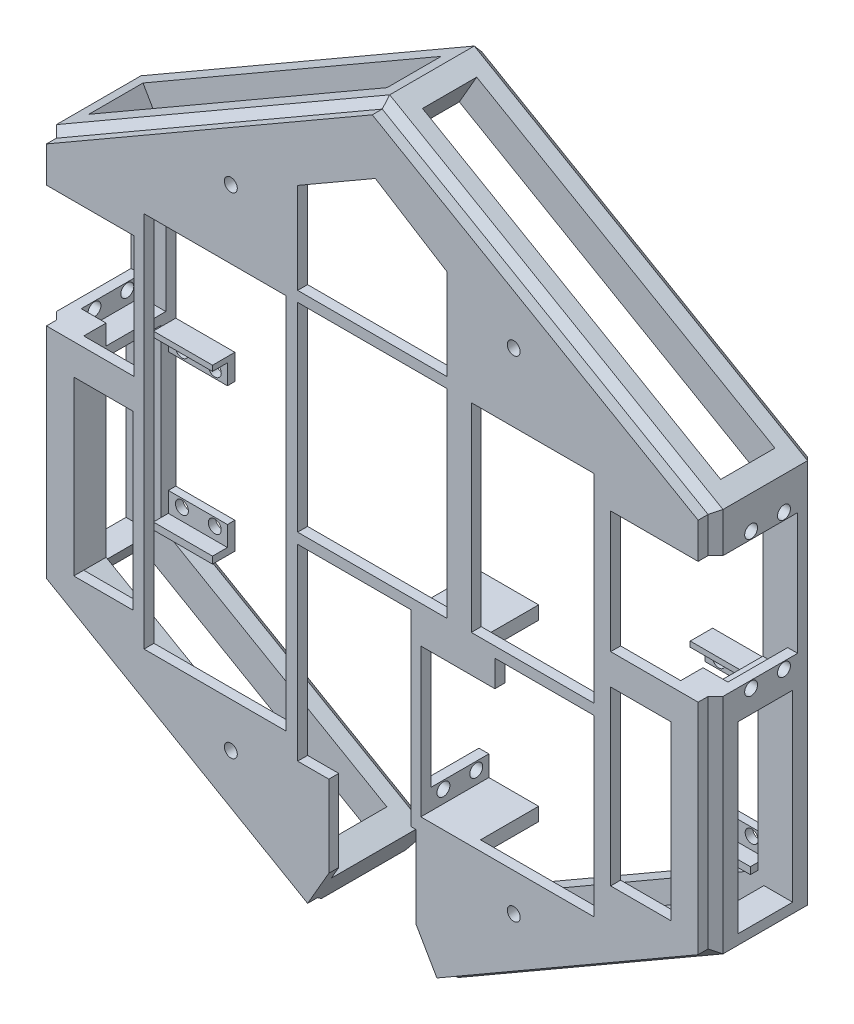
from build123d import *

# Parameters (mm, degrees)
BOSS_EXTRU_1_DEPTH           = 20
CHANFREIN1_SIZE              = 1.5
ESQUISSE4_W                  = 20
ESQUISSE4_H                  = 24.5
ENL_V_MAT_EXTRU_1_DEPTH      = 202.172397046
ENL_V_MAT_EXTRU_1_DEPTH_BACK = 10
ESQUISSE8_W                  = 10.9
ESQUISSE8_H                  = 69.214936071
ENL_V_MAT_EXTRU_3_DEPTH      = 7
ESQUISSE9_W                  = 10.9
ESQUISSE9_H                  = 69.214936071
ENL_V_MAT_EXTRU_4_DEPTH      = 7
ESQUISSE11_W                 = 11
ESQUISSE11_H                 = 69.214936071
ENL_V_MAT_EXTRU_5_DEPTH      = 7
ESQUISSE10_W                 = 11
ESQUISSE10_H                 = 69.214936071
ENL_V_MAT_EXTRU_6_DEPTH      = 7
BOSS_EXTRU_2_DEPTH           = 2
ESQUISSE18_W                 = 18.5
ESQUISSE18_H                 = 34.630653181
BOSS_EXTRU_5_DEPTH           = 30
ENL_V_START                  = -10
ESQUISSE20_W                 = 30
ESQUISSE20_H                 = 34.630653181
ENL_V_MAT_EXTRU_9_DEPTH      = 24
ENL_V_MAT_EXTRU_8_REACH      = 171.855
ESQUISSE19_W                 = 12.084
ESQUISSE19_H                 = 24.149
ESQUISSE22_W                 = 4.5
ESQUISSE22_H                 = 34.630653181
ENL_V_MAT_EXTRU_10_DEPTH     = 17.916
ESQUISSE23_W                 = 2
ESQUISSE23_H                 = 34.630653181
BOSS_EXTRU_6_DEPTH           = 17.916
ENL_V_MAT_EXTRU_11_REACH     = 171.855
ESQUISSE21_R                 = 1.3
ESQUISSE24_W                 = 12.084
ESQUISSE24_H                 = 4
ENL_V_MAT_EXTRU_12_DEPTH     = 3
ENL_V_START_2                = -18.116
ESQUISSE25_W                 = 4.5
ESQUISSE25_H                 = 34.630653181
ENL_V_MAT_EXTRU_13_DEPTH     = 18.116
ESQUISSE26_W                 = 2
ESQUISSE26_H                 = 34.630653181
BOSS_EXTRU_7_DEPTH           = 18.116
ENL_V_MAT_EXTRU_14_REACH     = 207.867
ESQUISSE27_R                 = 1.3
ENL_V_MAT_EXTRU_15_REACH     = 172.042
ESQUISSE28_W                 = 17.584
ESQUISSE28_H                 = 24.5
ESQUISSE29_W                 = 12.011314892
ESQUISSE29_H                 = 4
ENL_V_MAT_EXTRU_16_DEPTH     = 5
ESQUISSE30_W                 = 26.891
ESQUISSE30_H                 = 37.749
BOSS_EXTRU_8_DEPTH           = 13.684
ESQUISSE31_W                 = 11.684
ESQUISSE31_H                 = 37.749
ENL_V_MAT_EXTRU_18_DEPTH     = 10
ESQUISSE32_W                 = 16.891
ESQUISSE32_H                 = 24.149
ENL_V_MAT_EXTRU_19_DEPTH     = 11.684
ESQUISSE33_W                 = 14.891
ESQUISSE33_H                 = 6.8
ENL_V_MAT_EXTRU_20_DEPTH     = 11.684
ESQUISSE34_W                 = 11.684
ESQUISSE34_H                 = 2.682
BOSS_EXTRU_9_DEPTH           = 10
ESQUISSE35_R                 = 1.3
ENL_V_MAT_EXTRU_21_DEPTH     = 10
ESQUISSE36_W                 = 14.891
ESQUISSE36_H                 = 29.745214719
ENL_V_MAT_EXTRU_22_DEPTH     = 10
ESQUISSE37_R                 = 1.3
ENL_V_MAT_EXTRU_23_DEPTH     = 5
ENL_V_MAT_EXTRU_24_REACH     = 171.795
ESQUISSE38_W                 = 30
ESQUISSE38_H                 = 40
ENL_V_MAT_EXTRU_25_REACH     = 207.867
ESQUISSE39_W                 = 11
ESQUISSE39_H                 = 36.905484187
ESQUISSE40_W                 = 11
ESQUISSE40_H                 = 36.905484187
ENL_V_MAT_EXTRU_26_DEPTH     = 7
ESQUISSE41_W                 = 15
ESQUISSE41_H                 = 22
ENL_V_MAT_EXTRU_27_DEPTH     = 10
ESQUISSE42_W                 = 15
ESQUISSE42_H                 = 22
ENL_V_MAT_EXTRU_28_DEPTH     = 10
ESQUISSE43_W                 = 4.359796613
ESQUISSE43_H                 = 21.511824703
ENL_V_MAT_EXTRU_29_DEPTH     = 10
BOSS_EXTRU_10_REACH          = 164.107
ESQUISSE45_W                 = 24.622278159
ESQUISSE45_H                 = 40
ESQUISSE45_W_2               = 28.545366006
ESQUISSE45_H_2               = 75.789830022
ESQUISSE45_W_3               = 19.879423901
ESQUISSE45_H_3               = 35.067
ENL_V_MAT_EXTRU_33_DEPTH     = 10


with BuildPart() as part:
    # Esquisse1 → Boss.-Extru.1 (new body)
    with BuildSketch(Plane.XY):
        Polygon((-67, -38.682468036), (0, 0), (67, -38.682468036), (67, -116.047404107), (0, -154.729872143), (-67, -116.047404107), align=None)
        Polygon((0, -8.082903769), (60, -42.72391992), (60, -112.005952223), (0, -146.646968374), (-60, -112.005952223), (-60, -42.72391992), align=None, mode=Mode.SUBTRACT)
    extrude(amount=BOSS_EXTRU_1_DEPTH)

    # Chanfrein1
    chanfrein1_edges = [part.edges().sort_by_distance(p)[0] for p in [
        (33.5, -135.388638125, 20),
        (67, -77.364936071, 20),
        (33.5, -19.341234018, 20),
        (-33.5, -19.341234018, 20),
        (-30, -25.403411844, 0),
        (-60, -77.364936071, 0),
        (-30, -129.326460298, 0),
        (30, -129.326460298, 0),
        (60, -77.364936071, 0),
        (30, -25.403411844, 0),
        (-67, -77.364936071, 20),
        (-33.5, -19.341234018, 0),
        (33.5, -19.341234018, 0),
        (67, -77.364936071, 0),
        (-33.5, -135.388638125, 20),
        (33.5, -135.388638125, 0),
        (-33.5, -135.388638125, 0),
        (-67, -77.364936071, 0),
    ]]
    chamfer(chanfrein1_edges, length=CHANFREIN1_SIZE)

    # Esquisse4 → Enlèv. mat.-Extru.1 (cut, two sides)
    with BuildSketch(Plane(origin=(-60, 0, 0), x_dir=(0, 0, -1), z_dir=(1, 0, 0))) as enl_v_mat_extru_1_sk:
        with Locations((-13.5, -58.97391992)):
            Rectangle(ESQUISSE4_W, ESQUISSE4_H)
    extrude(amount=ENL_V_MAT_EXTRU_1_DEPTH, mode=Mode.SUBTRACT)
    extrude(enl_v_mat_extru_1_sk.sketch, amount=-ENL_V_MAT_EXTRU_1_DEPTH_BACK, mode=Mode.SUBTRACT)

    # Esquisse8 → Enlèv. mat.-Extru.3 (cut)
    with BuildSketch(Plane(origin=(0, 0, 0), x_dir=(0, 0, 1), z_dir=(-0.49999999999998623, 0.8660254037844466, 0))):
        with Locations((10, -38.757468036)):
            Rectangle(ESQUISSE8_W, ESQUISSE8_H)
    extrude(amount=-ENL_V_MAT_EXTRU_3_DEPTH, mode=Mode.SUBTRACT)

    # Esquisse9 → Enlèv. mat.-Extru.4 (cut)
    with BuildSketch(Plane(origin=(0, 0, 0), x_dir=(0, 0, -1), z_dir=(0.4999999999999863, 0.8660254037844466, 0))):
        with Locations((-10.05, -38.757468036)):
            Rectangle(ESQUISSE9_W, ESQUISSE9_H)
    extrude(amount=-ENL_V_MAT_EXTRU_4_DEPTH, mode=Mode.SUBTRACT)

    # Esquisse11 → Enlèv. mat.-Extru.5 (cut)
    with BuildSketch(Plane(origin=(67, -116.047404107, 0), x_dir=(0, 0, -1), z_dir=(0.499999999999995, -0.8660254037844415, 0))):
        with Locations((-10, -38.607468036)):
            Rectangle(ESQUISSE11_W, ESQUISSE11_H)
    extrude(amount=-ENL_V_MAT_EXTRU_5_DEPTH, mode=Mode.SUBTRACT)

    # Esquisse10 → Enlèv. mat.-Extru.6 (cut)
    with BuildSketch(Plane(origin=(-67, -116.047404107, 0), x_dir=(0, 0, 1), z_dir=(-0.500000000000004, -0.8660254037844363, 0))):
        with Locations((10, -38.257468036)):
            Rectangle(ESQUISSE10_W, ESQUISSE10_H)
    extrude(amount=-ENL_V_MAT_EXTRU_6_DEPTH, mode=Mode.SUBTRACT)

    # Esquisse13 → Boss.-Extru.2 (add)
    with BuildSketch(Plane.XY.offset(20)):
        Polygon((65.5, -115.181378703), (65.5, -39.548493439), (0, -1.732050808), (-65.5, -39.548493439), (-65.5, -115.181378703), (0, -152.997821335), align=None)
    extrude(amount=BOSS_EXTRU_2_DEPTH)

    # Esquisse18 → Boss.-Extru.5 (add)
    with BuildSketch(Plane.ZY.offset(-60)):
        with Locations((10.75, -94.690625633)):
            Rectangle(ESQUISSE18_W, ESQUISSE18_H)
    boss_extru_5 = extrude(amount=BOSS_EXTRU_5_DEPTH)

    # Symétrie5: Boss.-Extru.5 across plane
    add(boss_extru_5.mirror(Plane(origin=(0, 0, 0), x_dir=(0, 0, 1), z_dir=(1, 0, 0))))

    # Esquisse20 → Enlèv. mat.-Extru.9 (cut)
    with BuildSketch(Plane(origin=(0, 0, 20), x_dir=(-1, 0, 0), z_dir=(0, 0, -1)).offset(ENL_V_START)):
        with Locations((-45, -94.690625633)):
            Rectangle(ESQUISSE20_W, ESQUISSE20_H)
    enl_v_mat_extru_9 = extrude(amount=ENL_V_MAT_EXTRU_9_DEPTH, mode=Mode.SUBTRACT)

    # Esquisse19 → Enlèv. mat.-Extru.8 (cut, up to next)
    with BuildSketch(Plane(origin=(0, 0, 1.5), x_dir=(-1, 0, 0), z_dir=(0, 0, -1)), mode=Mode.PRIVATE) as enl_v_mat_extru_8_sk1:
        with Locations((-53.958, -94.536790537)):
            Rectangle(ESQUISSE19_W, ESQUISSE19_H)
    enl_v_mat_extru_8_tool1 = extrude(enl_v_mat_extru_8_sk1.sketch, amount=-ENL_V_MAT_EXTRU_8_REACH, mode=Mode.PRIVATE) & part.part
    enl_v_mat_extru_8 = enl_v_mat_extru_8_tool1.solids().sort_by_distance((53.958, -94.536791, 1.5))[0]
    add(enl_v_mat_extru_8, mode=Mode.SUBTRACT)

    # Esquisse22 → Enlèv. mat.-Extru.10 (cut)
    with BuildSketch(Plane.ZY.offset(-30)):
        with Locations((3.75, -94.690625633)):
            Rectangle(ESQUISSE22_W, ESQUISSE22_H)
    extrude(amount=-ENL_V_MAT_EXTRU_10_DEPTH, mode=Mode.SUBTRACT)

    # Esquisse23 → Boss.-Extru.6 (add)
    with BuildSketch(Plane(origin=(30, 0, 0), x_dir=(0, 0, -1), z_dir=(1, 0, 0))):
        with Locations((-21, -94.690625633)):
            Rectangle(ESQUISSE23_W, ESQUISSE23_H)
    extrude(amount=BOSS_EXTRU_6_DEPTH)

    # Esquisse21 → Enlèv. mat.-Extru.11 (cut, up to next)
    with BuildSketch(Plane(origin=(0, 0, 1.5), x_dir=(-1, 0, 0), z_dir=(0, 0, -1)), mode=Mode.PRIVATE) as enl_v_mat_extru_11_sk1:
        with Locations(Location((-50.656, -80.884290537, 0), (0, 0, 90))):
            Circle(ESQUISSE21_R)
    enl_v_mat_extru_11_tool1 = extrude(enl_v_mat_extru_11_sk1.sketch, amount=-ENL_V_MAT_EXTRU_11_REACH, mode=Mode.PRIVATE) & part.part
    # Esquisse21 → Enlèv. mat.-Extru.11 (cut, up to next)
    with BuildSketch(Plane(origin=(0, 0, 1.5), x_dir=(-1, 0, 0), z_dir=(0, 0, -1)), mode=Mode.PRIVATE) as enl_v_mat_extru_11_sk2:
        with Locations(Location((-57.26, -80.884290537, 0), (0, 0, 90))):
            Circle(ESQUISSE21_R)
    enl_v_mat_extru_11_tool2 = extrude(enl_v_mat_extru_11_sk2.sketch, amount=-ENL_V_MAT_EXTRU_11_REACH, mode=Mode.PRIVATE) & part.part
    # Esquisse21 → Enlèv. mat.-Extru.11 (cut, up to next)
    with BuildSketch(Plane(origin=(0, 0, 1.5), x_dir=(-1, 0, 0), z_dir=(0, 0, -1)), mode=Mode.PRIVATE) as enl_v_mat_extru_11_sk3:
        with Locations(Location((-50.656, -108.189290537, 0), (0, 0, 180))):
            Circle(ESQUISSE21_R)
    enl_v_mat_extru_11_tool3 = extrude(enl_v_mat_extru_11_sk3.sketch, amount=-ENL_V_MAT_EXTRU_11_REACH, mode=Mode.PRIVATE) & part.part
    # Esquisse21 → Enlèv. mat.-Extru.11 (cut, up to next)
    with BuildSketch(Plane(origin=(0, 0, 1.5), x_dir=(-1, 0, 0), z_dir=(0, 0, -1)), mode=Mode.PRIVATE) as enl_v_mat_extru_11_sk4:
        with Locations(Location((-57.26, -108.189290537, 0), (0, 0, 180))):
            Circle(ESQUISSE21_R)
    enl_v_mat_extru_11_tool4 = extrude(enl_v_mat_extru_11_sk4.sketch, amount=-ENL_V_MAT_EXTRU_11_REACH, mode=Mode.PRIVATE) & part.part
    enl_v_mat_extru_11_1 = enl_v_mat_extru_11_tool1.solids().sort_by_distance((50.656, -80.884291, 1.5))[0]
    add(enl_v_mat_extru_11_1, mode=Mode.SUBTRACT)
    enl_v_mat_extru_11_2 = enl_v_mat_extru_11_tool2.solids().sort_by_distance((57.26, -80.884291, 1.5))[0]
    add(enl_v_mat_extru_11_2, mode=Mode.SUBTRACT)
    enl_v_mat_extru_11_3 = enl_v_mat_extru_11_tool3.solids().sort_by_distance((50.656, -108.189291, 1.5))[0]
    add(enl_v_mat_extru_11_3, mode=Mode.SUBTRACT)
    enl_v_mat_extru_11_4 = enl_v_mat_extru_11_tool4.solids().sort_by_distance((57.26, -108.189291, 1.5))[0]
    add(enl_v_mat_extru_11_4, mode=Mode.SUBTRACT)
    enl_v_mat_extru_11 = enl_v_mat_extru_11_1 + enl_v_mat_extru_11_2 + enl_v_mat_extru_11_3 + enl_v_mat_extru_11_4  # Enlèv. mat.-Extru.11 as one shape, for the pattern or mirror that repeats it

    # Esquisse24 → Enlèv. mat.-Extru.12 (cut)
    with BuildSketch(Plane.XY.offset(6)):
        with Locations((53.958, -80.462290537)):
            Rectangle(ESQUISSE24_W, ESQUISSE24_H)
        with Locations((53.958, -108.611290537)):
            Rectangle(ESQUISSE24_W, ESQUISSE24_H)
    enl_v_mat_extru_12 = extrude(amount=-ENL_V_MAT_EXTRU_12_DEPTH, mode=Mode.SUBTRACT)

    # Symétrie13: Enlèv. mat.-Extru.9, Enlèv. mat.-Extru.8, Enlèv. mat.-Extru.11, Enlèv. mat.-Extru.12 across plane
    add(enl_v_mat_extru_9.mirror(Plane(origin=(0, 0, 0), x_dir=(0, 0, 1), z_dir=(1, 0, 0))), mode=Mode.SUBTRACT)
    add(enl_v_mat_extru_8.mirror(Plane(origin=(0, 0, 0), x_dir=(0, 0, 1), z_dir=(1, 0, 0))), mode=Mode.SUBTRACT)
    add(enl_v_mat_extru_11.mirror(Plane(origin=(0, 0, 0), x_dir=(0, 0, 1), z_dir=(1, 0, 0))), mode=Mode.SUBTRACT)
    add(enl_v_mat_extru_12.mirror(Plane(origin=(0, 0, 0), x_dir=(0, 0, 1), z_dir=(1, 0, 0))), mode=Mode.SUBTRACT)

    # Esquisse25 → Enlèv. mat.-Extru.13 (cut)
    with BuildSketch(Plane(origin=(-30, 0, 0), x_dir=(0, 0, -1), z_dir=(1, 0, 0)).offset(ENL_V_START_2)):
        with Locations((-3.75, -94.690625633)):
            Rectangle(ESQUISSE25_W, ESQUISSE25_H)
    extrude(amount=ENL_V_MAT_EXTRU_13_DEPTH, mode=Mode.SUBTRACT)

    # Esquisse26 → Boss.-Extru.7 (add)
    with BuildSketch(Plane.ZY.offset(30)):
        with Locations((21, -94.690625633)):
            Rectangle(ESQUISSE26_W, ESQUISSE26_H)
    extrude(amount=BOSS_EXTRU_7_DEPTH)

    # Esquisse27 → Enlèv. mat.-Extru.14 (cut, up to next)
    with BuildSketch(Plane(origin=(67, 0, 0), x_dir=(0, 0, -1), z_dir=(1, 0, 0)), mode=Mode.PRIVATE) as enl_v_mat_extru_14_sk1:
        with Locations(Location((-12.844, -45.29691992, 0), (0, 0, 90))):
            Circle(ESQUISSE27_R)
    enl_v_mat_extru_14_tool1 = extrude(enl_v_mat_extru_14_sk1.sketch, amount=-ENL_V_MAT_EXTRU_14_REACH, mode=Mode.PRIVATE) & part.part
    # Esquisse27 → Enlèv. mat.-Extru.14 (cut, up to next)
    with BuildSketch(Plane(origin=(67, 0, 0), x_dir=(0, 0, -1), z_dir=(1, 0, 0)), mode=Mode.PRIVATE) as enl_v_mat_extru_14_sk2:
        with Locations(Location((-6.24, -45.29691992, 0), (0, 0, 90))):
            Circle(ESQUISSE27_R)
    enl_v_mat_extru_14_tool2 = extrude(enl_v_mat_extru_14_sk2.sketch, amount=-ENL_V_MAT_EXTRU_14_REACH, mode=Mode.PRIVATE) & part.part
    # Esquisse27 → Enlèv. mat.-Extru.14 (cut, up to next)
    with BuildSketch(Plane(origin=(67, 0, 0), x_dir=(0, 0, -1), z_dir=(1, 0, 0)), mode=Mode.PRIVATE) as enl_v_mat_extru_14_sk3:
        with Locations(Location((-6.24, -72.65091992, 0), (0, 0, 90))):
            Circle(ESQUISSE27_R)
    enl_v_mat_extru_14_tool3 = extrude(enl_v_mat_extru_14_sk3.sketch, amount=-ENL_V_MAT_EXTRU_14_REACH, mode=Mode.PRIVATE) & part.part
    # Esquisse27 → Enlèv. mat.-Extru.14 (cut, up to next)
    with BuildSketch(Plane(origin=(67, 0, 0), x_dir=(0, 0, -1), z_dir=(1, 0, 0)), mode=Mode.PRIVATE) as enl_v_mat_extru_14_sk4:
        with Locations(Location((-12.844, -72.65091992, 0), (0, 0, 90))):
            Circle(ESQUISSE27_R)
    enl_v_mat_extru_14_tool4 = extrude(enl_v_mat_extru_14_sk4.sketch, amount=-ENL_V_MAT_EXTRU_14_REACH, mode=Mode.PRIVATE) & part.part
    enl_v_mat_extru_14_1 = enl_v_mat_extru_14_tool1.solids().sort_by_distance((67, -45.29692, 12.844))[0]
    add(enl_v_mat_extru_14_1, mode=Mode.SUBTRACT)
    enl_v_mat_extru_14_2 = enl_v_mat_extru_14_tool2.solids().sort_by_distance((67, -45.29692, 6.24))[0]
    add(enl_v_mat_extru_14_2, mode=Mode.SUBTRACT)
    enl_v_mat_extru_14_3 = enl_v_mat_extru_14_tool3.solids().sort_by_distance((67, -72.65092, 6.24))[0]
    add(enl_v_mat_extru_14_3, mode=Mode.SUBTRACT)
    enl_v_mat_extru_14_4 = enl_v_mat_extru_14_tool4.solids().sort_by_distance((67, -72.65092, 12.844))[0]
    add(enl_v_mat_extru_14_4, mode=Mode.SUBTRACT)
    enl_v_mat_extru_14 = enl_v_mat_extru_14_1 + enl_v_mat_extru_14_2 + enl_v_mat_extru_14_3 + enl_v_mat_extru_14_4  # Enlèv. mat.-Extru.14 as one shape, for the pattern or mirror that repeats it

    # Symétrie14: Enlèv. mat.-Extru.14 across plane
    add(enl_v_mat_extru_14.mirror(Plane(origin=(0, 0, 0), x_dir=(0, 0, 1), z_dir=(1, 0, 0))), mode=Mode.SUBTRACT)

    # Esquisse28 → Enlèv. mat.-Extru.15 (cut, up to next)
    with BuildSketch(Plane.XY.offset(22), mode=Mode.PRIVATE) as enl_v_mat_extru_15_sk1:
        with Locations((56.708, -58.97391992)):
            Rectangle(ESQUISSE28_W, ESQUISSE28_H)
    enl_v_mat_extru_15_tool1 = extrude(enl_v_mat_extru_15_sk1.sketch, amount=-ENL_V_MAT_EXTRU_15_REACH, mode=Mode.PRIVATE) & part.part
    # Esquisse28 → Enlèv. mat.-Extru.15 (cut, up to next)
    with BuildSketch(Plane.XY.offset(22), mode=Mode.PRIVATE) as enl_v_mat_extru_15_sk2:
        with Locations((-56.708, -58.97391992)):
            Rectangle(ESQUISSE28_W, ESQUISSE28_H)
    enl_v_mat_extru_15_tool2 = extrude(enl_v_mat_extru_15_sk2.sketch, amount=-ENL_V_MAT_EXTRU_15_REACH, mode=Mode.PRIVATE) & part.part
    add(enl_v_mat_extru_15_tool1.solids().sort_by_distance((56.708, -58.97392, 22))[0], mode=Mode.SUBTRACT)
    add(enl_v_mat_extru_15_tool2.solids().sort_by_distance((-56.708, -58.97392, 22))[0], mode=Mode.SUBTRACT)

    # Esquisse29 → Enlèv. mat.-Extru.16 (cut)
    with BuildSketch(Plane.ZY.offset(-60)):
        with Locations((9.505657446, -44.72391992)):
            Rectangle(ESQUISSE29_W, ESQUISSE29_H)
        with Locations((9.505657446, -73.22391992)):
            Rectangle(ESQUISSE29_W, ESQUISSE29_H)
    enl_v_mat_extru_16 = extrude(amount=-ENL_V_MAT_EXTRU_16_DEPTH, mode=Mode.SUBTRACT)

    # Symétrie15: Enlèv. mat.-Extru.16 across plane
    add(enl_v_mat_extru_16.mirror(Plane(origin=(0, 0, 0), x_dir=(0, 0, 1), z_dir=(1, 0, 0))), mode=Mode.SUBTRACT)

    # Esquisse30 → Boss.-Extru.8 (add)
    with BuildSketch(Plane.XY.offset(22)):
        with Locations((21.201447373, -102.870418219)):
            Rectangle(ESQUISSE30_W, ESQUISSE30_H)
    extrude(amount=-BOSS_EXTRU_8_DEPTH)

    # Esquisse31 → Enlèv. mat.-Extru.18 (cut)
    with BuildSketch(Plane(origin=(34.646947373, 0, 0), x_dir=(0, 0, -1), z_dir=(1, 0, 0)).offset(ENL_V_START)):
        with Locations((-14.158, -102.870418219)):
            Rectangle(ESQUISSE31_W, ESQUISSE31_H)
    extrude(amount=ENL_V_MAT_EXTRU_18_DEPTH, mode=Mode.SUBTRACT)

    # Esquisse32 → Enlèv. mat.-Extru.19 (cut)
    with BuildSketch(Plane(origin=(0, 0, 8.316), x_dir=(-1, 0, 0), z_dir=(0, 0, -1))):
        with Locations((-16.201447373, -102.870418219)):
            Rectangle(ESQUISSE32_W, ESQUISSE32_H)
    extrude(amount=-ENL_V_MAT_EXTRU_19_DEPTH, mode=Mode.SUBTRACT)

    # Esquisse33 → Enlèv. mat.-Extru.20 (cut)
    with BuildSketch(Plane(origin=(0, 0, 8.316), x_dir=(-1, 0, 0), z_dir=(0, 0, -1))):
        with Locations((-17.201447373, -118.344918219)):
            Rectangle(ESQUISSE33_W, ESQUISSE33_H)
        with Locations((-17.201447373, -87.395918219)):
            Rectangle(ESQUISSE33_W, ESQUISSE33_H)
    extrude(amount=-ENL_V_MAT_EXTRU_20_DEPTH, mode=Mode.SUBTRACT)

    # Esquisse34 → Boss.-Extru.9 (add)
    with BuildSketch(Plane(origin=(9.755947373, 0, 0), x_dir=(0, 0, -1), z_dir=(1, 0, 0))):
        with Locations((-14.158, -120.403918219)):
            Rectangle(ESQUISSE34_W, ESQUISSE34_H)
        with Locations((-14.158, -85.336918219)):
            Rectangle(ESQUISSE34_W, ESQUISSE34_H)
    extrude(amount=BOSS_EXTRU_9_DEPTH)

    # Esquisse35 → Enlèv. mat.-Extru.21 (cut)
    with BuildSketch(Plane.ZY.offset(-7.755947373)):
        with Locations(Location((17.46, -116.522918219, 0), (0, 0, 270))):
            Circle(ESQUISSE35_R)
        with Locations(Location((10.856, -116.522918219, 0), (0, 0, 270))):
            Circle(ESQUISSE35_R)
        with Locations((17.46, -89.217918219)):
            Circle(ESQUISSE35_R)
        with Locations((10.856, -89.217918219)):
            Circle(ESQUISSE35_R)
    extrude(amount=-ENL_V_MAT_EXTRU_21_DEPTH, mode=Mode.SUBTRACT)

    # Esquisse36 → Enlèv. mat.-Extru.22 (cut)
    with BuildSketch(Plane(origin=(0, 0, 20), x_dir=(-1, 0, 0), z_dir=(0, 0, -1))):
        with Locations((-17.201447373, -104.19031086)):
            Rectangle(ESQUISSE36_W, ESQUISSE36_H)
    extrude(amount=-ENL_V_MAT_EXTRU_22_DEPTH, mode=Mode.SUBTRACT)

    # Esquisse37 → Enlèv. mat.-Extru.23 (cut)
    with BuildSketch(Plane.XY.offset(22)):
        with Locations((28.43376724, -28.114091826)):
            Circle(ESQUISSE37_R)
        with Locations((-28.43376724, -28.114091826)):
            Circle(ESQUISSE37_R)
        with Locations((28.43376724, -126.615748014)):
            Circle(ESQUISSE37_R)
        with Locations((-28.43376724, -126.615748014)):
            Circle(ESQUISSE37_R)
    extrude(amount=-ENL_V_MAT_EXTRU_23_DEPTH, mode=Mode.SUBTRACT)

    # Esquisse38 → Enlèv. mat.-Extru.24 (cut, up to next)
    with BuildSketch(Plane(origin=(0, 0, 20), x_dir=(-1, 0, 0), z_dir=(0, 0, -1)), mode=Mode.PRIVATE) as enl_v_mat_extru_24_sk1:
        with Locations((0, -61.88084657)):
            Rectangle(ESQUISSE38_W, ESQUISSE38_H)
    enl_v_mat_extru_24_tool1 = extrude(enl_v_mat_extru_24_sk1.sketch, amount=-ENL_V_MAT_EXTRU_24_REACH, mode=Mode.PRIVATE) & part.part
    add(enl_v_mat_extru_24_tool1.solids().sort_by_distance((0, -61.880847, 20))[0], mode=Mode.SUBTRACT)

    # Enlèv. mat.-Extru.25: up to this face of the body (flat: up to its plane)
    enl_v_mat_extru_25_end = Plane(part.part.faces().sort_by_distance((-60, -90.417213625, 11.342496139))[0])
    # Esquisse39 → Enlèv. mat.-Extru.25 (cut, up to the picked face)
    with BuildSketch(Plane.ZY.offset(67), mode=Mode.PRIVATE) as enl_v_mat_extru_25_sk1:
        with Locations((10, -95.594662013)):
            Rectangle(ESQUISSE39_W, ESQUISSE39_H)
    enl_v_mat_extru_25_tool1 = split(extrude(enl_v_mat_extru_25_sk1.sketch, amount=-ENL_V_MAT_EXTRU_25_REACH, mode=Mode.PRIVATE), bisect_by=enl_v_mat_extru_25_end, keep=Keep.BOTH, mode=Mode.PRIVATE)
    add(enl_v_mat_extru_25_tool1.solids().sort_by(Axis((-67, -95.594662, 10), (1, 0, 0)))[0], mode=Mode.SUBTRACT)

    # Esquisse40 → Enlèv. mat.-Extru.26 (cut)
    with BuildSketch(Plane(origin=(67, 0, 0), x_dir=(0, 0, -1), z_dir=(1, 0, 0))):
        with Locations((-10, -95.594662013)):
            Rectangle(ESQUISSE40_W, ESQUISSE40_H)
    extrude(amount=-ENL_V_MAT_EXTRU_26_DEPTH, mode=Mode.SUBTRACT)

    # Esquisse41 → Enlèv. mat.-Extru.27 (cut)
    with BuildSketch(Plane(origin=(67, -116.047404107, 0), x_dir=(0.8660254037844396, 0.4999999999999983, 0), z_dir=(0.4999999999999983, -0.8660254037844396, 0))):
        with Locations((-68.998910668, 11)):
            Rectangle(ESQUISSE41_W, ESQUISSE41_H)
    extrude(amount=-ENL_V_MAT_EXTRU_27_DEPTH, mode=Mode.SUBTRACT)

    # Esquisse42 → Enlèv. mat.-Extru.28 (cut)
    with BuildSketch(Plane(origin=(-67, -116.047404107, 0), x_dir=(0.8660254037844372, -0.5000000000000027, 0), z_dir=(-0.5000000000000027, -0.8660254037844373, 0))):
        with Locations((68.998910668, 11)):
            Rectangle(ESQUISSE42_W, ESQUISSE42_H)
    extrude(amount=-ENL_V_MAT_EXTRU_28_DEPTH, mode=Mode.SUBTRACT)


with BuildPart() as enl_v_mat_extru_28_piece_1:
    # of the separate pieces the step leaves, piece 1, a body of its own (enl_v_mat_extru_28_pieces)
    add(part.part.solids().sort_by_distance((-67, -38.682468036, 1.5))[0])

    # Esquisse44 → Boss.-Extru.10 (add, up to next)
    with BuildSketch(Plane(origin=(0, 0, 15.5), x_dir=(-1, 0, 0), z_dir=(0, 0, -1)), mode=Mode.PRIVATE) as boss_extru_10_sk1:
        Polygon((-13.740381057, -146.796859441), (-10.240381057, -140.734681614), (-14.570508076, -138.234681614), (-18.070508076, -144.296859441), align=None)
    boss_extru_10_tool1 = extrude(boss_extru_10_sk1.sketch, amount=BOSS_EXTRU_10_REACH, mode=Mode.PRIVATE) - enl_v_mat_extru_28_piece_1.part
    # Esquisse44 → Boss.-Extru.10 (add, up to next)
    with BuildSketch(Plane(origin=(0, 0, 15.5), x_dir=(-1, 0, 0), z_dir=(0, 0, -1)), mode=Mode.PRIVATE) as boss_extru_10_sk2:
        Polygon((13.740381057, -146.796859441), (10.240381057, -140.734681614), (14.570508076, -138.234681614), (18.070508076, -144.296859441), align=None)
    boss_extru_10_tool2 = extrude(boss_extru_10_sk2.sketch, amount=BOSS_EXTRU_10_REACH, mode=Mode.PRIVATE) - enl_v_mat_extru_28_piece_1.part
    add(boss_extru_10_tool1.solids().sort_by_distance((14.155445, -142.515771, 15.5))[0])
    add(boss_extru_10_tool2.solids().sort_by_distance((-14.155445, -142.515771, 15.5))[0])

    # Esquisse45 → Enlèv. mat.-Extru.33 (cut)
    with BuildSketch(Plane(origin=(0, 0, 20), x_dir=(-1, 0, 0), z_dir=(0, 0, -1))):
        with Locations((-32.215232195, -61.88084657)):
            Rectangle(ESQUISSE45_W, ESQUISSE45_H)
        with Locations((31.610787121, -79.775761581)):
            Rectangle(ESQUISSE45_W_2, ESQUISSE45_H_2)
        with Locations((-34.586659324, -101.529418219)):
            Rectangle(ESQUISSE45_W_3, ESQUISSE45_H_3)
        Polygon((-15, -21.516567609), (-15, -39.791837259), (15, -39.791837259), (15, -21.516567609), (-0.611225984, -12.503422085), align=None)
        Polygon((15, -83.995918219), (-7.755947373, -83.995918219), (-7.755947373, -121.744918219), (-8.740381057, -121.744918219), (-8.740381057, -138.136605403), (0, -143.182866759), (8.740381057, -138.136605403), (8.740381057, -121.744918219), (15, -121.744918219), align=None)
    extrude(amount=-ENL_V_MAT_EXTRU_33_DEPTH, mode=Mode.SUBTRACT)


with BuildPart() as enl_v_mat_extru_28_piece_2:
    # of the separate pieces the step leaves, piece 2, a body of its own (enl_v_mat_extru_28_pieces)
    add(part.part.solids().sort_by_distance((0, -154.729872143, 1.5))[0])

    # Esquisse43 → Enlèv. mat.-Extru.29 (cut)
    with BuildSketch(Plane(origin=(-67, -116.047404107, 0), x_dir=(0.8660254037844372, -0.5000000000000027, 0), z_dir=(-0.5000000000000027, -0.8660254037844373, 0))):
        with Locations((76.972755728, 9.916727065)):
            Rectangle(ESQUISSE43_W, ESQUISSE43_H)
    extrude(amount=-ENL_V_MAT_EXTRU_29_DEPTH, mode=Mode.SUBTRACT)


solid = enl_v_mat_extru_28_piece_1.part
